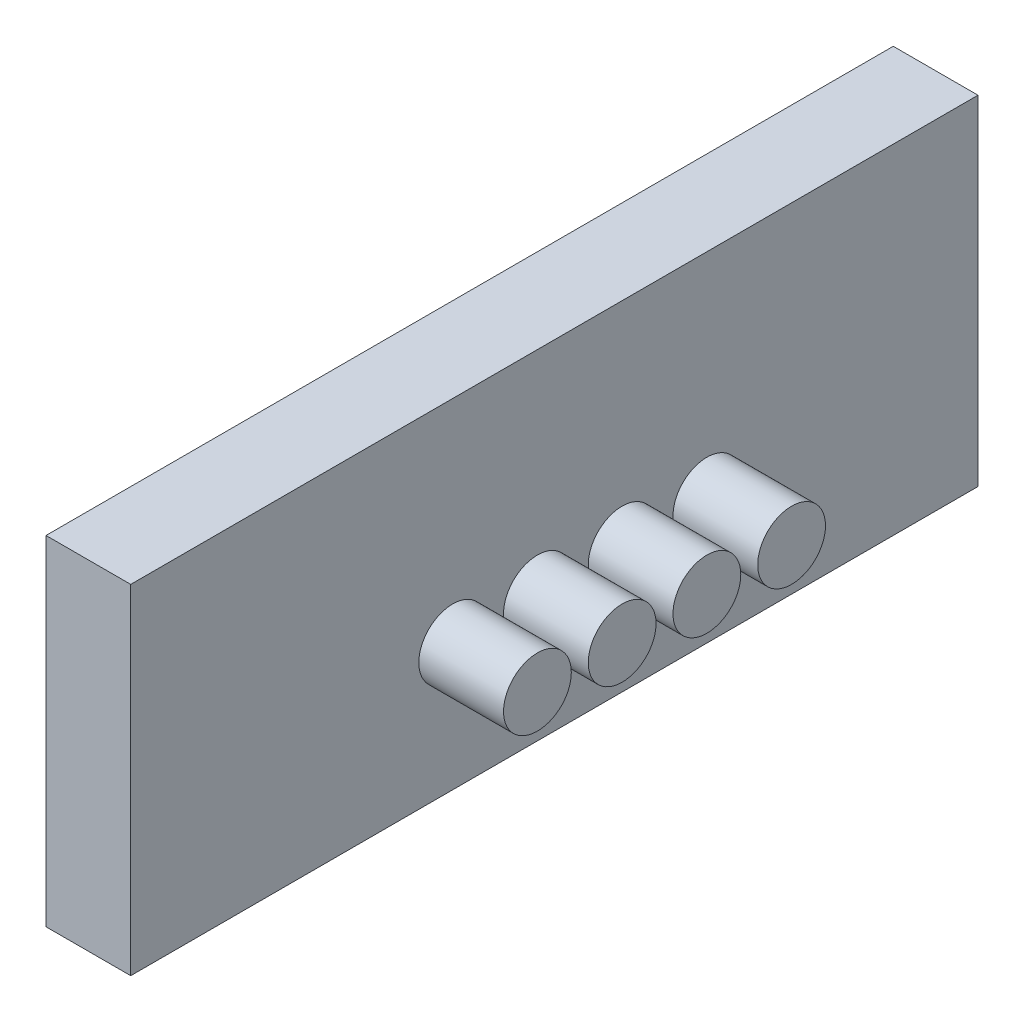
from build123d import *

# Parameters (mm, degrees)
SKETCH1_W           = 100
SKETCH1_H           = 40
BOSS_EXTRUDE1_DEPTH = 10
SKETCH2_R           = 4
BOSS_EXTRUDE2_DEPTH = 10


with BuildPart() as part:
    # Sketch1 → Boss-Extrude1 (new body)
    with BuildSketch(Plane(origin=(0, 0, 0), x_dir=(0, 0, -1), z_dir=(1, 0, 0))):
        Rectangle(SKETCH1_W, SKETCH1_H)
    extrude(amount=BOSS_EXTRUDE1_DEPTH)

    # Sketch2 → Boss-Extrude2 (add)
    with BuildSketch(Plane(origin=(10, 0, 0), x_dir=(0, 0, -1), z_dir=(1, 0, 0))):
        with Locations((18, -5)):
            Circle(SKETCH2_R)
        with Locations((8, -5)):
            Circle(SKETCH2_R)
        with Locations((-2, -5)):
            Circle(SKETCH2_R)
        with Locations((-12, -5)):
            Circle(SKETCH2_R)
    extrude(amount=BOSS_EXTRUDE2_DEPTH)


solid = part.part
